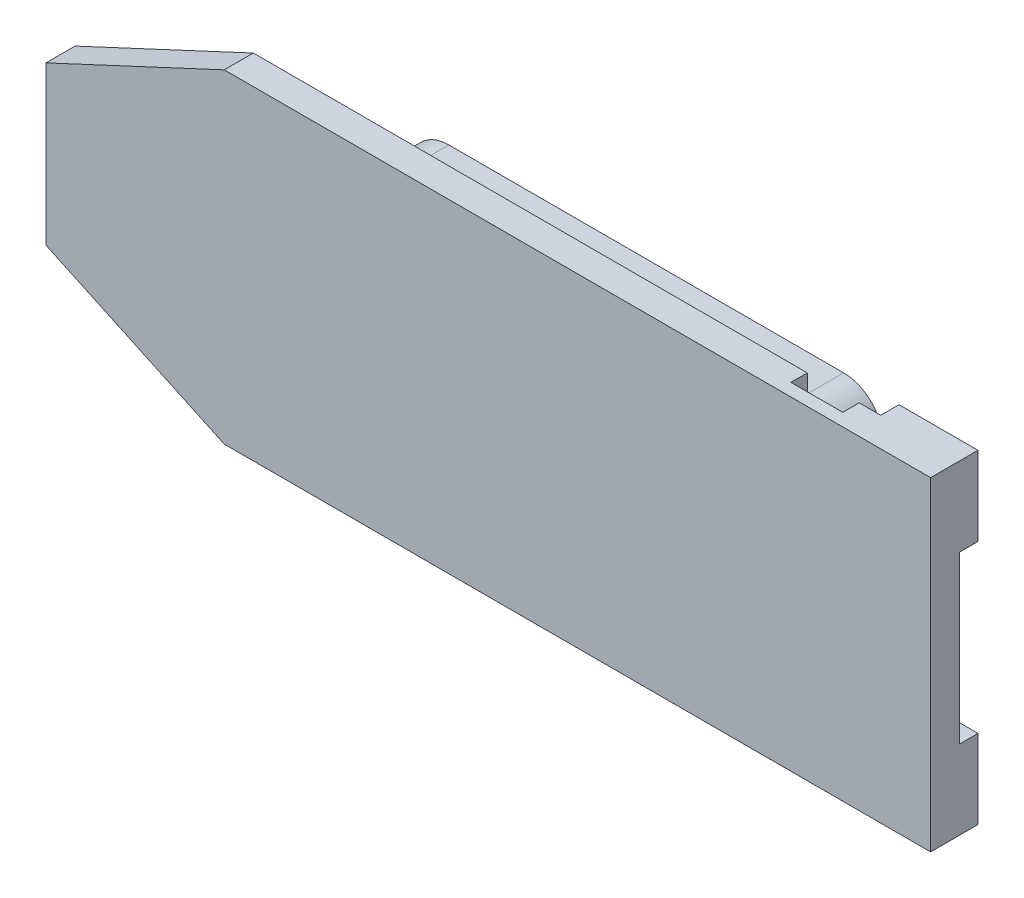
from build123d import *

# Parameters (mm, degrees)
EXTRUDE1_DEPTH     = 2.34
SKETCH2_W          = 6.35
SKETCH2_H          = 6.35
SKETCH2_R          = 1.09
EXTRUDE2_DEPTH     = 1.47
SKETCH3_W          = 4.17
SKETCH3_H          = 4.57
SKETCH3_W_2        = 4.57
SKETCH3_H_2        = 4.17
CUT_EXTRUDE1_DEPTH = 1.32
FILLET1_R          = 0.81
SKETCH4_W          = 38.1
SKETCH4_H          = 15.88
SKETCH4_R          = 1.37
EXTRUDE3_DEPTH     = 6.55
FILLET2_R          = 3.18


with BuildPart() as part:
    # Sketch1 → Extrude1 (new body)
    with BuildSketch(Plane.XY):
        Polygon((-35.56, -6.35), (-35.56, 6.35), (-21.23, 13.03), (35.56, 13.03), (35.56, -13.03), (-21.23, -13.03), align=None)
    extrude(amount=EXTRUDE1_DEPTH)

    # Sketch2 → Extrude2 (add)
    with BuildSketch(Plane(origin=(0, 0, 0), x_dir=(-1, 0, 0), z_dir=(0, 0, -1))):
        with Locations((-32.385, 9.855)):
            Rectangle(SKETCH2_W, SKETCH2_H)
        with Locations((-32.385, 9.855)):
            Circle(SKETCH2_R, mode=Mode.SUBTRACT)
        with Locations((-32.385, -9.855)):
            Rectangle(SKETCH2_W, SKETCH2_H)
        with Locations((-32.385, -9.855)):
            Circle(SKETCH2_R, mode=Mode.SUBTRACT)
        with Locations((26.665, 0)):
            Rectangle(SKETCH2_W, SKETCH2_H)
        with Locations((26.665, 0)):
            Circle(SKETCH2_R, mode=Mode.SUBTRACT)
    extrude(amount=EXTRUDE2_DEPTH)

    # Sketch3 → Cut-Extrude1 (cut)
    with BuildSketch(Plane(origin=(0, 0, 0), x_dir=(-1, 0, 0), z_dir=(0, 0, -1))):
        with Locations((-25.395, -10.745)):
            Rectangle(SKETCH3_W, SKETCH3_H)
        with Locations((-25.395, 10.745)):
            Rectangle(SKETCH3_W, SKETCH3_H)
        with Locations((33.275, 0)):
            Rectangle(SKETCH3_W_2, SKETCH3_H_2)
    extrude(amount=-CUT_EXTRUDE1_DEPTH, mode=Mode.SUBTRACT)

    # Fillet1
    fillet1_edges = [part.edges().sort_by_distance(p)[0] for p in [
        (27.48, -8.46, 0.66),
        (23.31, -8.46, 0.66),
        (27.48, 8.46, 0.66),
        (23.31, 8.46, 0.66),
        (-30.99, -2.085, 0.66),
        (-30.99, 2.085, 0.66),
    ]]
    fillet(fillet1_edges, radius=FILLET1_R)

    # Sketch4 → Extrude3 (add)
    with BuildSketch(Plane(origin=(0, 0, 0), x_dir=(-1, 0, 0), z_dir=(0, 0, -1))):
        with Locations((-3.81, 0)):
            Rectangle(SKETCH4_W, SKETCH4_H)
        with Locations((-16.51, 0)):
            Circle(SKETCH4_R, mode=Mode.SUBTRACT)
        with Locations((8.89, 0)):
            Circle(SKETCH4_R, mode=Mode.SUBTRACT)
    extrude(amount=EXTRUDE3_DEPTH)

    # Fillet2
    fillet2_edges = [part.edges().sort_by_distance(p)[0] for p in [
        (22.86, 7.94, -3.275),
        (22.86, -7.94, -3.275),
        (-15.24, -7.94, -3.275),
        (-15.24, 7.94, -3.275),
    ]]
    fillet(fillet2_edges, radius=FILLET2_R)


solid = part.part
